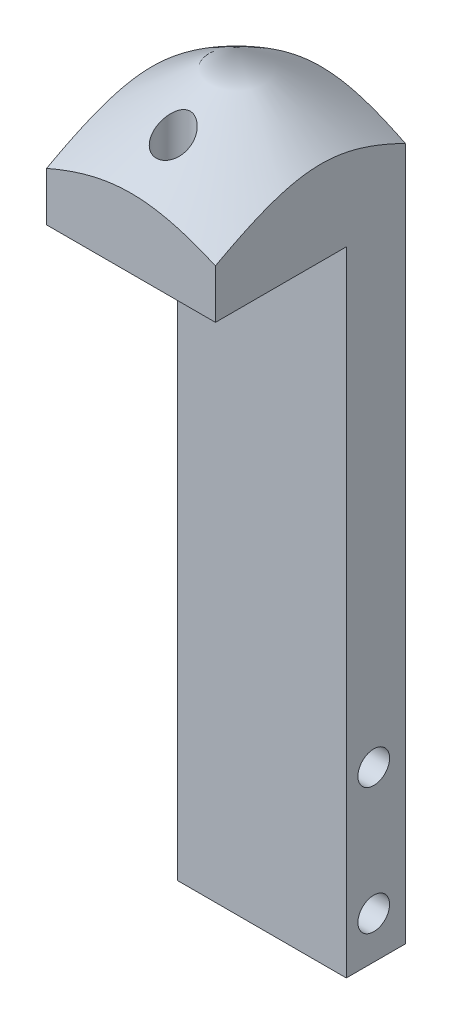
from build123d import *

# Parameters (mm, degrees)
BOSS_EXTRUDE1_DEPTH         = 12.7
F_1_4_20_TAPPED_HOLE1_D     = 5.1054
F_3_16_0_1875_DOWEL_HOLE1_D = 4.7625


with BuildPart() as part:
    # Sketch1 → Boss-Extrude1 (new body, symmetric)
    with BuildSketch(Plane(origin=(0, 0, 0), x_dir=(0, 0, -1), z_dir=(1, 0, 0))):
        Polygon((8.89, -95.25), (8.89, 22.225), (-19.685, 22.225), (-19.685, 0), (0, 0), (0, -95.25), align=None)
    extrude(amount=BOSS_EXTRUDE1_DEPTH, both=True)

    # Sketch2 → Cut-Revolve4 (revolve, cut)
    with BuildSketch(Plane(origin=(0, 0, 0), x_dir=(0, 0, -1), z_dir=(1, 0, 0))):
        Polygon((-26.697108117, 5.566910104), (-3.81, 21.592635735), (-3.81, 22.225), (-26.697108117, 22.225), align=None)
    revolve(axis=Axis((0, 21.592635735, 3.81), (0, 1, 0)), mode=Mode.SUBTRACT)

    # 1/4-20 Tapped Hole1 (through all)
    with Locations(Plane(origin=(0, 0, 0), x_dir=(-1, 0, 0), z_dir=(0, -1, 0))):
        with Locations((0, -13.335)):
            Hole(F_1_4_20_TAPPED_HOLE1_D / 2)

    # 3/16 (0.1875) Dowel Hole1 (through all)
    with Locations(Plane(origin=(12.7, 0, 0), x_dir=(0, 0, -1), z_dir=(1, 0, 0))):
        with Locations((4.1275, -88.9), (4.1275, -69.85)):
            Hole(F_3_16_0_1875_DOWEL_HOLE1_D / 2)


solid = part.part
